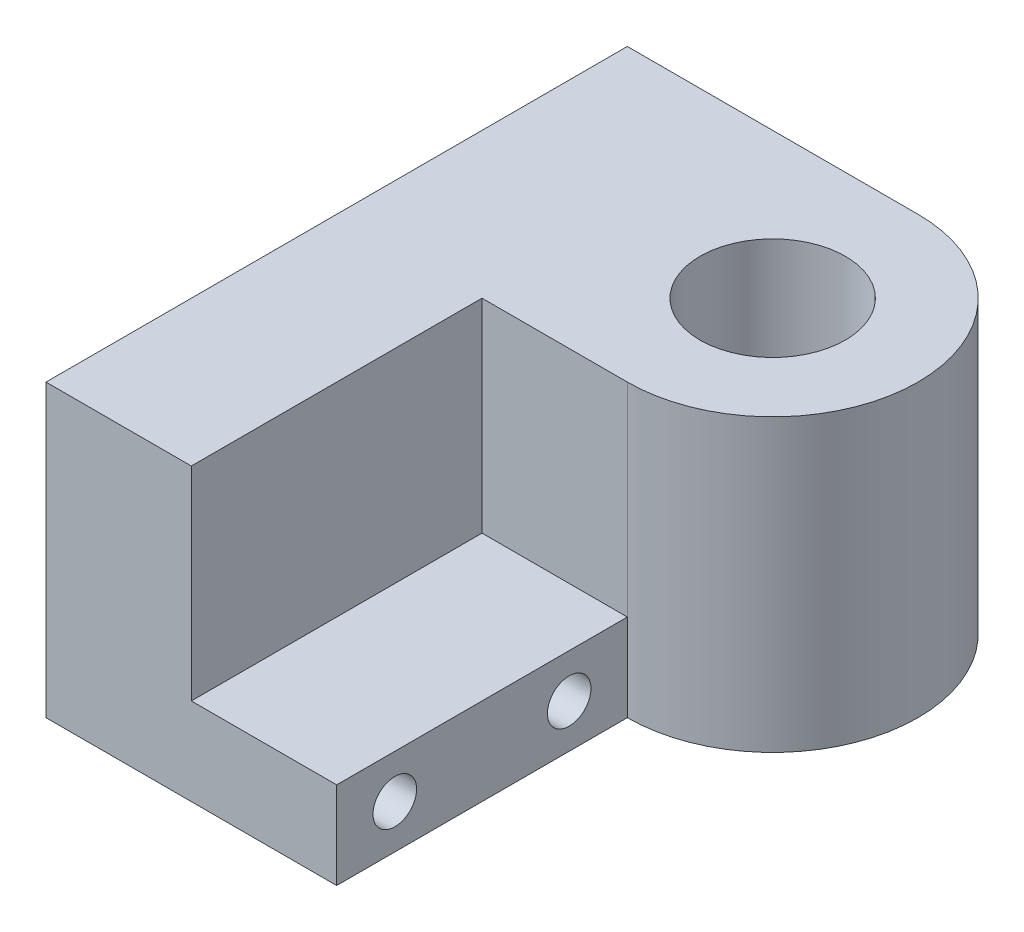
from build123d import *

# Parameters (mm, degrees)
CROQUIS3_R              = 25
SALIENTE_EXTRUIR2_DEPTH = 100
CROQUIS3_3_W            = 50
CROQUIS3_3_H            = 100
SALIENTE_EXTRUIR3_DEPTH = 30
CROQUIS4_R              = 7.5
CORTAR_EXTRUIR1_DEPTH   = 207.155281281


with BuildPart() as part:
    # Croquis3 → Saliente-Extruir2 (new body)
    with BuildSketch(Plane(origin=(0, 0, 0), x_dir=(1, 0, 0), z_dir=(0, 1, 0))):
        with BuildLine():
            ThreePointArc((0, -50), (50, 0), (0, 50))
            Line((0, 50), (-100, 50))
            Line((-100, 50), (-100, -150))
            Line((-100, -150), (-50, -150))
            Line((-50, -150), (-50, -50))
            Line((-50, -50), (0, -50))
        make_face()
        Circle(CROQUIS3_R, mode=Mode.SUBTRACT)
    extrude(amount=SALIENTE_EXTRUIR2_DEPTH)

    # Croquis3_3 → Saliente-Extruir3 (add)
    with BuildSketch(Plane(origin=(0, 0, 0), x_dir=(1, 0, 0), z_dir=(0, 1, 0))):
        with Locations((-25, -100)):
            Rectangle(CROQUIS3_3_W, CROQUIS3_3_H)
    extrude(amount=SALIENTE_EXTRUIR3_DEPTH)

    # Croquis4 → Cortar-Extruir1 (cut, through all)
    with BuildSketch(Plane(origin=(0, 0, 0), x_dir=(0, 0, -1), z_dir=(1, 0, 0))):
        with Locations((-130, 15)):
            Circle(CROQUIS4_R)
        with Locations((-70, 15)):
            Circle(CROQUIS4_R)
    extrude(amount=-CORTAR_EXTRUIR1_DEPTH, mode=Mode.SUBTRACT)


solid = part.part
